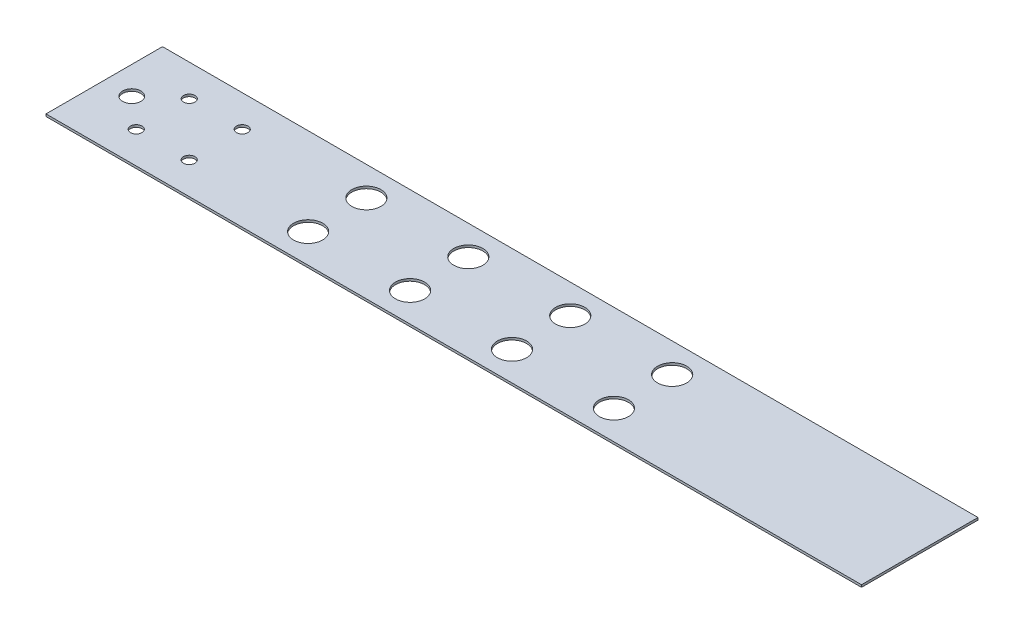
from build123d import *

# Parameters (mm, degrees)
ESQUISSE1_W             = 355.6
ESQUISSE1_H             = 50.8
BOSS_EXTRU_1_DEPTH      = 1
ESQUISSE2_R             = 3.96875
ENL_V_MAT_EXTRU_1_DEPTH = 1
ESQUISSE3_R             = 2.5
ENL_V_MAT_EXTRU_2_DEPTH = 2
ESQUISSE4_R             = 6.35
ENL_V_MAT_EXTRU_3_DEPTH = 2


with BuildPart() as part:
    # Esquisse1 → Boss.-Extru.1 (new body)
    with BuildSketch(Plane(origin=(0, 0, 0), x_dir=(1, 0, 0), z_dir=(0, 1, 0))):
        Rectangle(ESQUISSE1_W, ESQUISSE1_H)
    extrude(amount=BOSS_EXTRU_1_DEPTH)

    # Esquisse2 → Enlèv. mat.-Extru.1 (cut)
    with BuildSketch(Plane(origin=(0, 1, 0), x_dir=(1, 0, 0), z_dir=(0, 1, 0))):
        with Locations((-165.8, 0)):
            Circle(ESQUISSE2_R)
    extrude(amount=-ENL_V_MAT_EXTRU_1_DEPTH, mode=Mode.SUBTRACT)

    # Esquisse3 → Enlèv. mat.-Extru.2 (cut)
    with BuildSketch(Plane(origin=(0, 1, 0), x_dir=(1, 0, 0), z_dir=(0, 1, 0))):
        with Locations((-152.3, 11.55)):
            Circle(ESQUISSE3_R)
        with Locations((-129.2, 11.55)):
            Circle(ESQUISSE3_R)
        with Locations((-129.2, -11.55)):
            Circle(ESQUISSE3_R)
        with Locations((-152.3, -11.55)):
            Circle(ESQUISSE3_R)
    extrude(amount=-ENL_V_MAT_EXTRU_2_DEPTH, mode=Mode.SUBTRACT)

    # Esquisse4 → Enlèv. mat.-Extru.3 (cut)
    with BuildSketch(Plane(origin=(0, 1, 0), x_dir=(1, 0, 0), z_dir=(0, 1, 0))):
        with Locations((-76.2, 12.7)):
            Circle(ESQUISSE4_R)
        with Locations((12.7, 12.7)):
            Circle(ESQUISSE4_R)
        with Locations((12.7, -12.7)):
            Circle(ESQUISSE4_R)
        with Locations((-76.2, -12.7)):
            Circle(ESQUISSE4_R)
        with Locations((-31.75, 12.7)):
            Circle(ESQUISSE4_R)
        with Locations((57.15, 12.7)):
            Circle(ESQUISSE4_R)
        with Locations((57.15, -12.7)):
            Circle(ESQUISSE4_R)
        with Locations((-31.75, -12.7)):
            Circle(ESQUISSE4_R)
    extrude(amount=-ENL_V_MAT_EXTRU_3_DEPTH, mode=Mode.SUBTRACT)


solid = part.part
